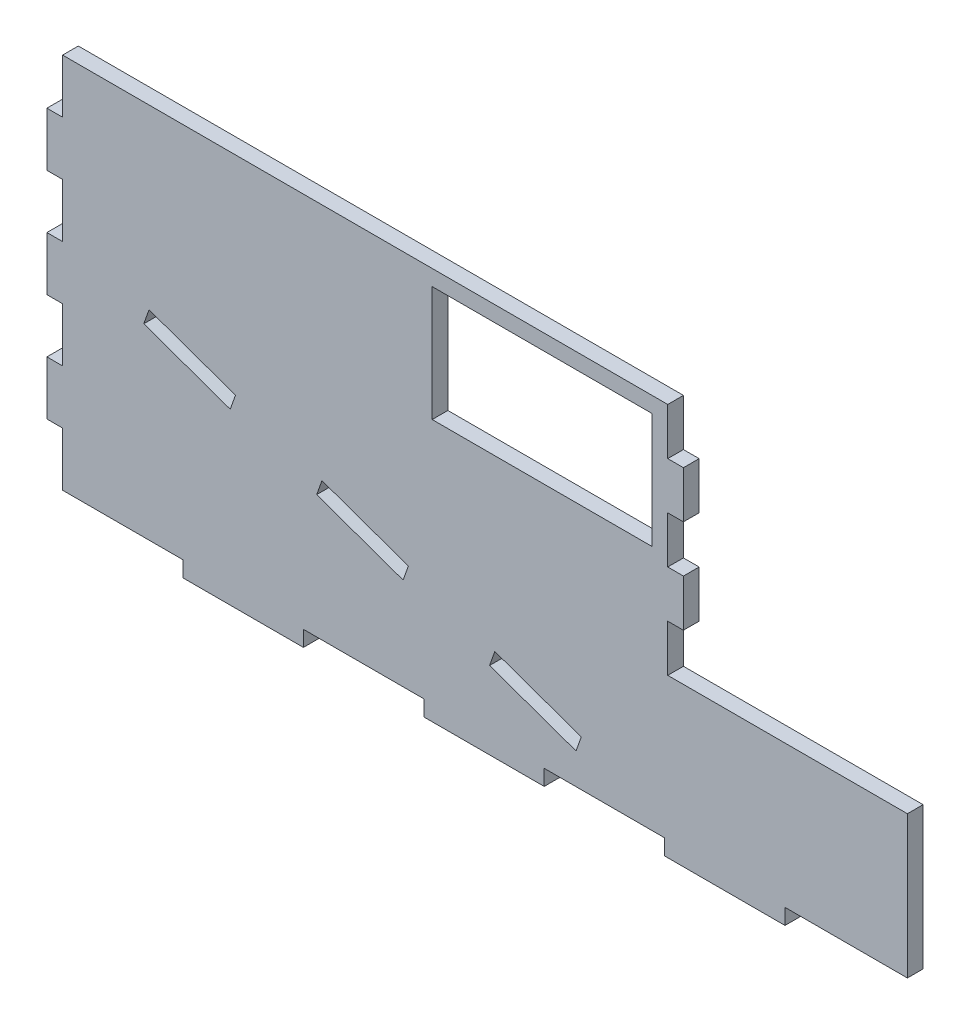
from build123d import *

# Parameters (mm, degrees)
SKETCH1_W           = 115.6
SKETCH1_H           = 72
BOSS_EXTRUDE1_DEPTH = 3
CUT_EXTRUDE1_REACH  = 5
SKETCH2_W           = 42
SKETCH2_H           = 22
SKETCH3_W           = 3
SKETCH3_H           = 8.964
SKETCH3_H_2         = 10.285714
BOSS_EXTRUDE2_DEPTH = 3
SKETCH4_W           = 45.782864491
SKETCH4_H           = 27.18
BOSS_EXTRUDE3_DEPTH = 3
SKETCH5_W           = 23
SKETCH5_H           = 3
BOSS_EXTRUDE4_DEPTH = 3


with BuildPart() as part:
    # Sketch1 → Boss-Extrude1 (new body)
    with BuildSketch(Plane.XY):
        with Locations((57.8, 36)):
            Rectangle(SKETCH1_W, SKETCH1_H)
        Polygon((16.514285714, 38.123846184), (15.508587017, 35.297440316), (32.022872733, 29.421286499), (33.02857143, 32.247692367), align=None, mode=Mode.SUBTRACT)
        Polygon((49.542857146, 26.37153855), (48.537158448, 23.545132682), (65.051444164, 17.668978865), (66.057142861, 20.495384733), align=None, mode=Mode.SUBTRACT)
        Polygon((82.571428577, 14.619230916), (81.56572988, 11.792825048), (98.080015595, 5.916671232), (99.085714292, 8.743077099), align=None, mode=Mode.SUBTRACT)
    extrude(amount=BOSS_EXTRUDE1_DEPTH)

    # Sketch2 → Cut-Extrude1 (cut, up to next)
    with BuildSketch(Plane.XY.offset(3), mode=Mode.PRIVATE) as cut_extrude1_sk1:
        with Locations((91.6, 58)):
            Rectangle(SKETCH2_W, SKETCH2_H)
    cut_extrude1_tool1 = extrude(cut_extrude1_sk1.sketch, amount=-CUT_EXTRUDE1_REACH, mode=Mode.PRIVATE) & part.part
    add(cut_extrude1_tool1.solids().sort_by_distance((91.6, 58, 3))[0], mode=Mode.SUBTRACT)

    # Sketch3 → Boss-Extrude2 (add)
    with BuildSketch(Plane.XY.offset(3)):
        with Locations((117.1, 58.554)):
            Rectangle(SKETCH3_W, SKETCH3_H)
        with Locations((117.1, 40.626)):
            Rectangle(SKETCH3_W, SKETCH3_H)
        with Locations((-1.5, 56.571428714)):
            Rectangle(SKETCH3_W, SKETCH3_H_2)
        with Locations((-1.5, 36.000000714)):
            Rectangle(SKETCH3_W, SKETCH3_H_2)
        with Locations((-1.5, 15.428572714)):
            Rectangle(SKETCH3_W, SKETCH3_H_2)
    extrude(amount=-BOSS_EXTRUDE2_DEPTH)

    # Sketch4 → Boss-Extrude3 (add)
    with BuildSketch(Plane.XY.offset(3)):
        with Locations((138.491432246, 13.59)):
            Rectangle(SKETCH4_W, SKETCH4_H)
    extrude(amount=-BOSS_EXTRUDE3_DEPTH)

    # Sketch5 → Boss-Extrude4 (add)
    with BuildSketch(Plane.XY.offset(3)):
        with Locations((34.5, -1.5)):
            Rectangle(SKETCH5_W, SKETCH5_H)
        with Locations((80.5, -1.5)):
            Rectangle(SKETCH5_W, SKETCH5_H)
        with Locations((126.5, -1.5)):
            Rectangle(SKETCH5_W, SKETCH5_H)
    extrude(amount=-BOSS_EXTRUDE4_DEPTH)


solid = part.part
